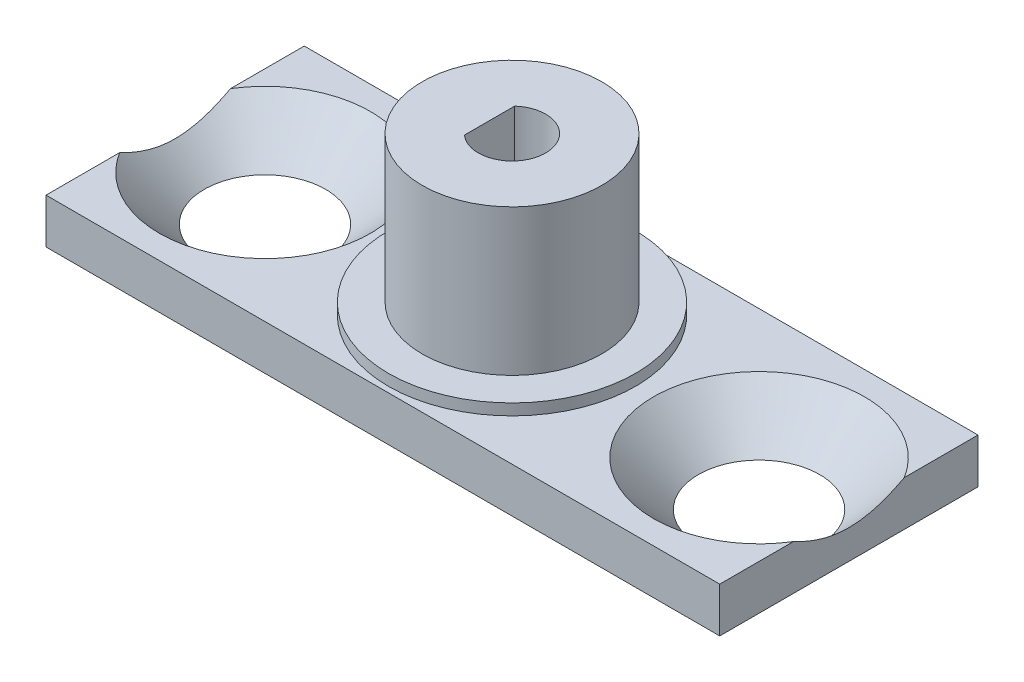
from build123d import *

# Parameters (mm, degrees)
SKETCH1_W                                    = 30
SKETCH1_H                                    = 11.5
BOSS_EXTRUDE1_DEPTH                          = 2
SKETCH2_R                                    = 5.5
BOSS_EXTRUDE2_DEPTH                          = 0.5
SKETCH3_R                                    = 4
BOSS_EXTRUDE3_DEPTH                          = 6.5
CUT_EXTRUDE1_DEPTH                           = 7
CSK_FOR_M4_COUNTERSUNK_FLAT_HEAD_SCR_2_COUNT = 2
CSK_FOR_M4_COUNTERSUNK_FLAT_HEAD_SCR_2_PITCH = 22


with BuildPart() as part:
    # Sketch1 → Boss-Extrude1 (new body)
    with BuildSketch(Plane(origin=(0, 0, 0), x_dir=(1, 0, 0), z_dir=(0, 1, 0))):
        Rectangle(SKETCH1_W, SKETCH1_H)
    extrude(amount=BOSS_EXTRUDE1_DEPTH)

    # Sketch2 → Boss-Extrude2 (add)
    with BuildSketch(Plane(origin=(0, 2, 0), x_dir=(1, 0, 0), z_dir=(0, 1, 0))):
        Circle(SKETCH2_R)
    extrude(amount=BOSS_EXTRUDE2_DEPTH)

    # Sketch3 → Boss-Extrude3 (add)
    with BuildSketch(Plane(origin=(0, 2.5, 0), x_dir=(1, 0, 0), z_dir=(0, 1, 0))):
        Circle(SKETCH3_R)
    extrude(amount=BOSS_EXTRUDE3_DEPTH)

    # Sketch4 → Cut-Extrude1 (cut)
    with BuildSketch(Plane(origin=(0, 9, 0), x_dir=(1, 0, 0), z_dir=(0, 1, 0))):
        with BuildLine():
            Line((-1, 1.118033989), (-1, -1.118033989))
            ThreePointArc((-1, -1.118033989), (1.5, 0), (-1, 1.118033989))
        make_face()
    extrude(amount=-CUT_EXTRUDE1_DEPTH, mode=Mode.SUBTRACT)

    # Sketch6 → CSK for M4 Countersunk Flat Head Screw1 (revolve, cut)
    with BuildSketch(Plane(origin=(11, 2, 0), x_dir=(0, 0, 1), z_dir=(1, 0, 0))):
        Polygon((0, 0), (0, 3.351936393), (2.25, 2), (2.25, 2.45), (4.7, 0), align=None)
    csk_for_m4_countersunk_flat_head_screw1 = revolve(axis=Axis((11, 8.35, 0), (0, -1, 0)), mode=Mode.SUBTRACT)

    # CSK for M4 Countersunk Flat Head Scr 2: CSK for M4 Countersunk Flat Head Screw1 ×2
    with Locations(*[(-i * CSK_FOR_M4_COUNTERSUNK_FLAT_HEAD_SCR_2_PITCH, 0, 0) for i in range(1, CSK_FOR_M4_COUNTERSUNK_FLAT_HEAD_SCR_2_COUNT)]):
        add(csk_for_m4_countersunk_flat_head_screw1, mode=Mode.SUBTRACT)


solid = part.part
